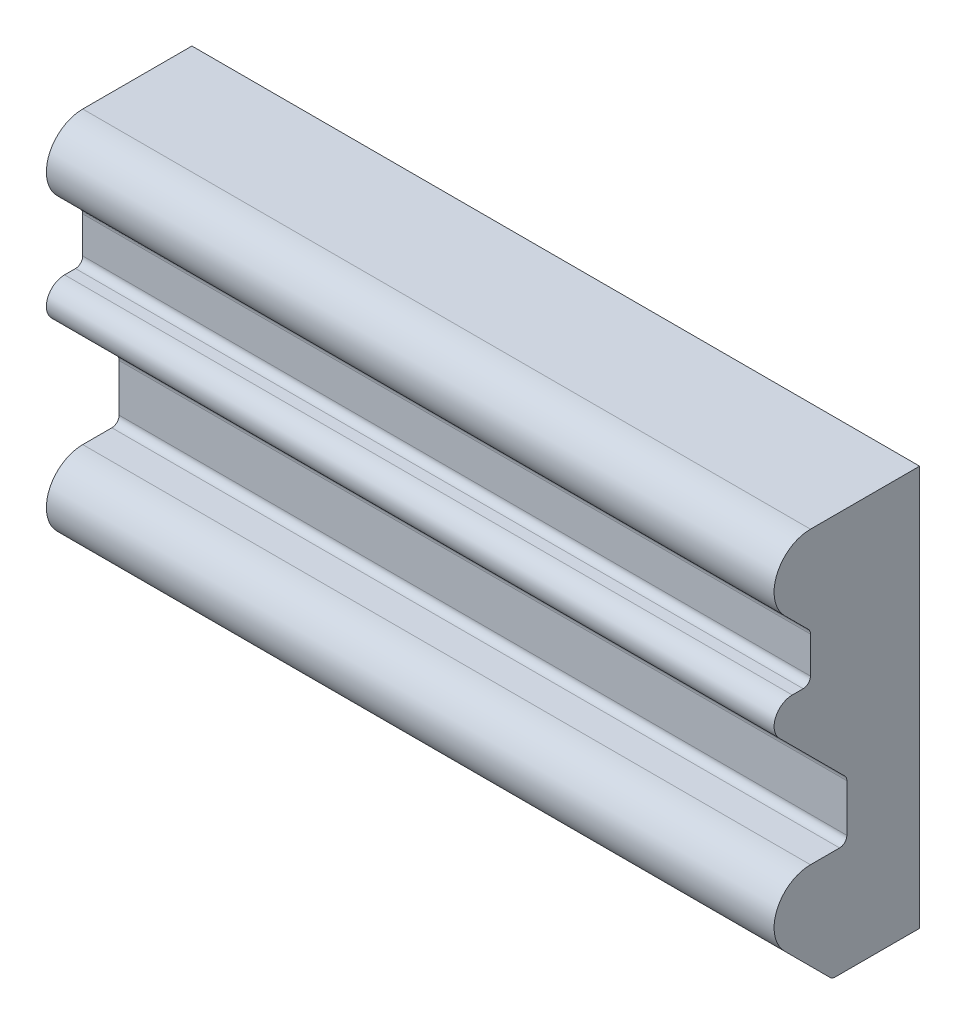
from build123d import *

# Parameters (mm, degrees)
SALIENTE_EXTRUIR1_DEPTH = 200


with BuildPart() as part:
    # Croquis1 → Saliente-Extruir1 (new body)
    with BuildSketch(Plane(origin=(0, 0, 0), x_dir=(0, 0, -1), z_dir=(1, 0, 0))):
        with BuildLine():
            Line((0, 0), (-23.183766184, 0))
            ThreePointArc((-23.183766184, 0), (-23.949133049, 0.152240935), (-24.597979746, 0.585786438))
            Line((-24.597979746, 0.585786438), (-37.071067812, 13.058874503))
            ThreePointArc((-37.071067812, 13.058874503), (-39.238795325, 23.956776639), (-30, 30.129942315))
            Line((-30, 30.129942315), (-22, 30.129942315))
            ThreePointArc((-22, 30.129942315), (-20.585786438, 30.715728753), (-20, 32.129942315))
            Line((-20, 32.129942315), (-20, 45.129942315))
            ThreePointArc((-20, 45.129942315), (-20.152240935, 45.89530918), (-20.585786438, 46.544155877))
            Line((-20.585786438, 46.544155877), (-38.535533906, 64.493903346))
            ThreePointArc((-38.535533906, 64.493903346), (-39.619397663, 69.942854413), (-35, 73.029437252))
            Line((-35, 73.029437252), (-32, 73.029437252))
            ThreePointArc((-32, 73.029437252), (-30.585786438, 73.615223689), (-30, 75.029437252))
            Line((-30, 75.029437252), (-30, 85.029437252))
            ThreePointArc((-30, 85.029437252), (-30.152240935, 85.794804116), (-30.585786438, 86.443650814))
            Line((-30.585786438, 86.443650814), (-37.071067812, 92.928932188))
            ThreePointArc((-37.071067812, 92.928932188), (-39.238795325, 103.826834324), (-30, 110))
            Line((-30, 110), (0, 110))
            Line((0, 110), (0, 0))
        make_face()
    extrude(amount=SALIENTE_EXTRUIR1_DEPTH)


solid = part.part
